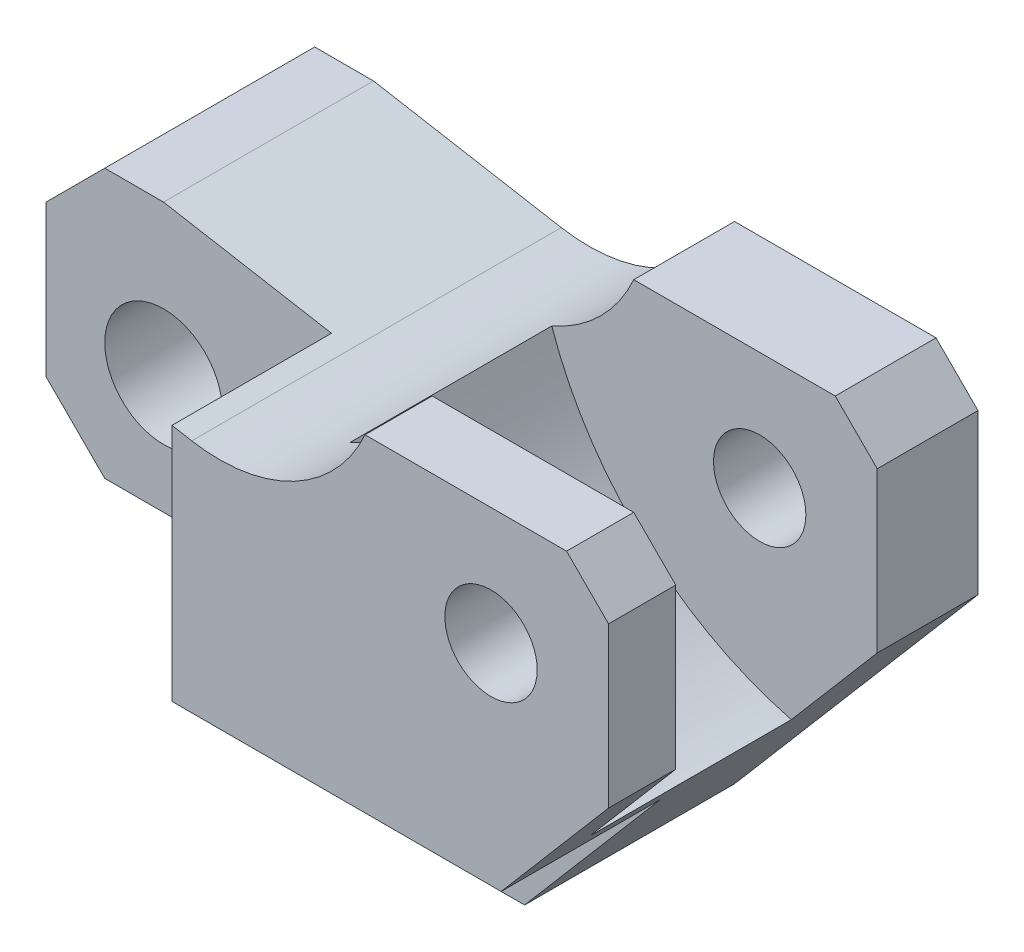
from build123d import *

# Parameters (mm, degrees)
SKETCH1_R               = 7
BOSS_EXTRUDE1_DEPTH     = 44
SKETCH1_2_R             = 7
BOSS_EXTRUDE2_DEPTH     = 44
CUT_EXTRUDE1_DEPTH      = 1
CUT_EXTRUDE1_DEPTH_BACK = 19
SKETCH4_W               = 50.710370583
SKETCH4_H               = 19
CUT_EXTRUDE2_DEPTH      = 52
SKETCH5_R               = 5.5
CUT_EXTRUDE3_DEPTH      = 45
CUT_EXTRUDE4_DEPTH      = 24


with BuildPart() as part:
    # Sketch1 → Boss-Extrude1 (new body)
    with BuildSketch(Plane.XY):
        with BuildLine():
            Line((-7, -14), (25.575538911, -14))
            ThreePointArc((25.575538911, -14), (28.840774692, -15.213413768), (30.521177653, -18.264705882))
            ThreePointArc((30.521177653, -18.264705882), (32.858007856, -26.115672061), (37.296980053, -33))
            Line((37.296980053, -33), (43, -33))
            Line((43, -33), (72, 1))
            Line((72, 1), (72, 20))
            Line((72, 20), (67, 25))
            Line((67, 25), (43, 25))
            ThreePointArc((43, 25), (34.561098706, 15.982044142), (22.361380836, 14.057085233))
            Line((22.361380836, 14.057085233), (0, 18))
            Line((0, 18), (-7, 18))
            Line((-7, 18), (-14, 11))
            Line((-14, 11), (-14, -7))
            Line((-14, -7), (-7, -14))
        make_face()
        Circle(SKETCH1_R, mode=Mode.SUBTRACT)
    extrude(amount=BOSS_EXTRUDE1_DEPTH)

    # Sketch1_2 → Boss-Extrude2 (add)
    with BuildSketch(Plane.XY):
        with BuildLine():
            Line((-7, -14), (25.575538911, -14))
            ThreePointArc((25.575538911, -14), (28.840774692, -15.213413768), (30.521177653, -18.264705882))
            ThreePointArc((30.521177653, -18.264705882), (32.858007856, -26.115672061), (37.296980053, -33))
            Line((37.296980053, -33), (43, -33))
            Line((43, -33), (72, 1))
            Line((72, 1), (72, 20))
            Line((72, 20), (67, 25))
            Line((67, 25), (43, 25))
            ThreePointArc((43, 25), (34.561098706, 15.982044142), (22.361380836, 14.057085233))
            Line((22.361380836, 14.057085233), (0, 18))
            Line((0, 18), (-7, 18))
            Line((-7, 18), (-14, 11))
            Line((-14, 11), (-14, -7))
            Line((-14, -7), (-7, -14))
        make_face()
        Circle(SKETCH1_2_R, mode=Mode.SUBTRACT)
    extrude(amount=BOSS_EXTRUDE2_DEPTH)

    # Sketch3 → Cut-Extrude1 (cut, two sides)
    with BuildSketch(Plane.XY.offset(44)) as cut_extrude1_sk:
        Polygon((-150.317212119, -14), (25.575538911, -14), (59.205882353, -14), (235.098633383, -14), (235.098633383, -365.78550206), (-150.317212119, -365.78550206), align=None)
    extrude(amount=CUT_EXTRUDE1_DEPTH, mode=Mode.SUBTRACT)
    extrude(cut_extrude1_sk.sketch, amount=-CUT_EXTRUDE1_DEPTH_BACK, mode=Mode.SUBTRACT)

    # Sketch4 → Cut-Extrude2 (cut, through all)
    with BuildSketch(Plane(origin=(0, 18, 0), x_dir=(1, 0, 0), z_dir=(0, 1, 0))):
        with Locations((-5.355185292, -34.5)):
            Rectangle(SKETCH4_W, SKETCH4_H)
    extrude(amount=-CUT_EXTRUDE2_DEPTH, mode=Mode.SUBTRACT)

    # Sketch5 → Cut-Extrude3 (cut, through all)
    with BuildSketch(Plane.XY.offset(44)):
        with Locations((58, 11)):
            Circle(SKETCH5_R)
    extrude(amount=-CUT_EXTRUDE3_DEPTH, mode=Mode.SUBTRACT)

    # Sketch9 → Cut-Extrude4 (cut)
    with BuildSketch(Plane(origin=(0, 0, 12), x_dir=(-1, 0, 0), z_dir=(0, 0, -1))):
        with BuildLine():
            Line((-72, 20), (-67, 25))
            Line((-67, 25), (-43, 25))
            ThreePointArc((-43, 25), (-39.021244343, 19.259333621), (-33.236936549, 15.344294617))
            ThreePointArc((-33.236936549, 15.344294617), (-44.184262982, -1.419294771), (-61.764705882, -11))
            Line((-61.764705882, -11), (-72, 1))
            Line((-72, 1), (-72, 20))
        make_face()
    extrude(amount=-CUT_EXTRUDE4_DEPTH, mode=Mode.SUBTRACT)


solid = part.part
